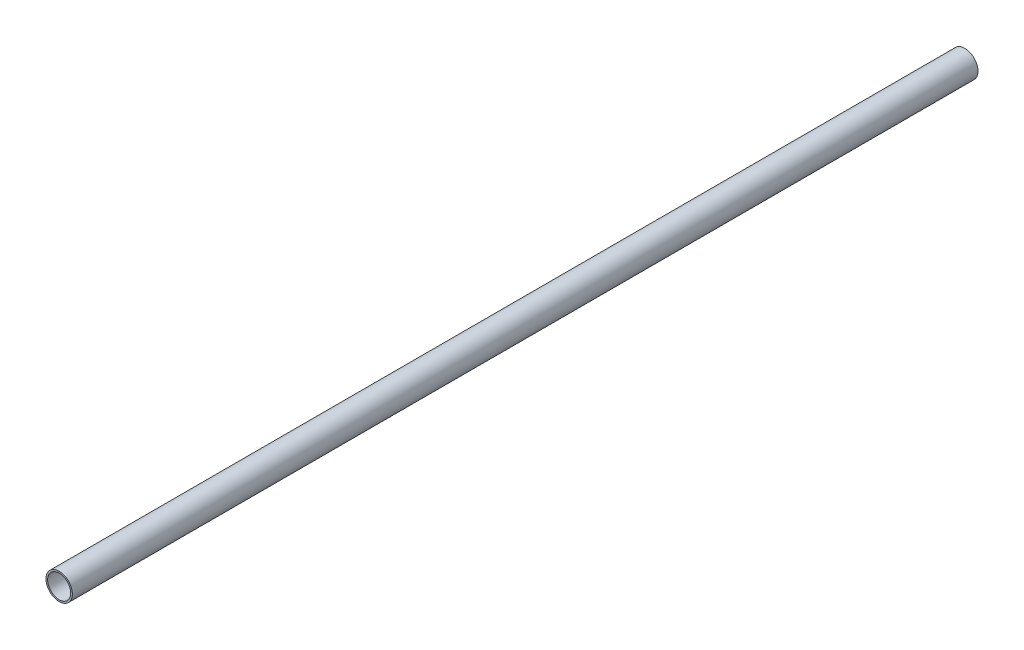
from build123d import *

# Parameters (mm, degrees)
SKETCH1_R           = 8
SKETCH1_R_2         = 7
BOSS_EXTRUDE1_DEPTH = 550


with BuildPart() as part:
    # Sketch1 → Boss-Extrude1 (new body)
    with BuildSketch(Plane.XY):
        Circle(SKETCH1_R)
        Circle(SKETCH1_R_2, mode=Mode.SUBTRACT)
    extrude(amount=BOSS_EXTRUDE1_DEPTH)


solid = part.part
